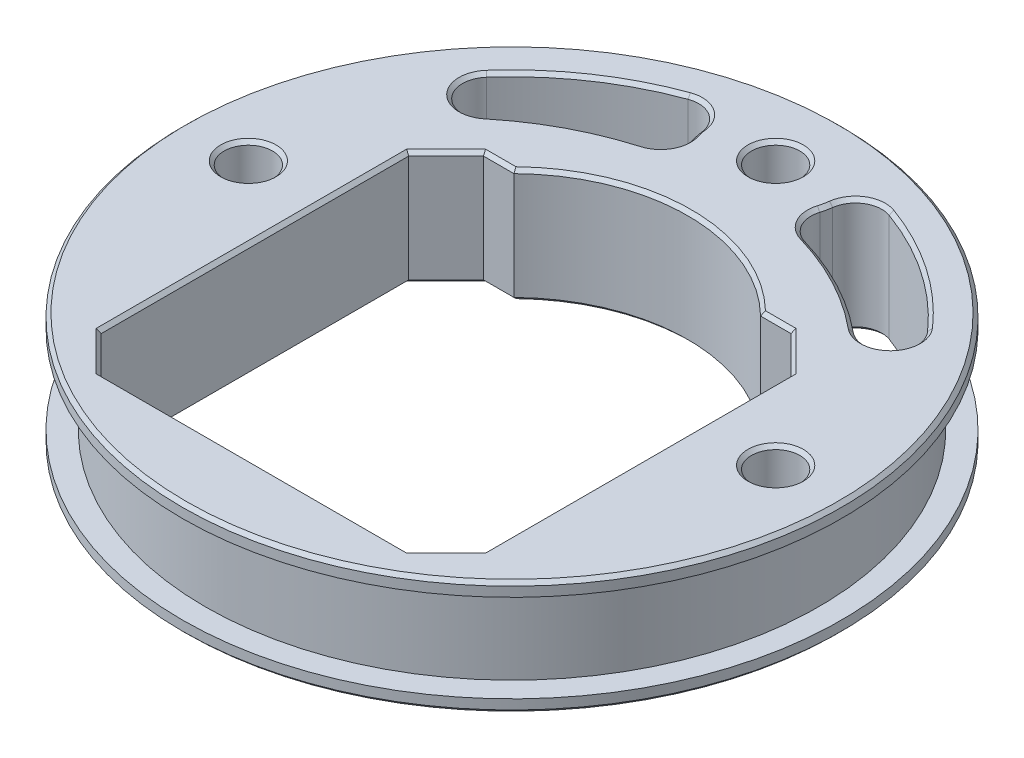
from build123d import *

# Parameters (mm, degrees)
SKETCH1_R               = 37.5
SKETCH1_R_2             = 2.75
BOSS_EXTRUDE1_DEPTH     = 6.5
SKETCH2_R               = 44.9
SKETCH2_R_2             = 34.9
CUT_EXTRUDE_THIN1_DEPTH = 5
CHAMFER1_SIZE           = 0.4
CHAMFER2_SIZE           = 0.4


with BuildPart() as part:
    # Sketch1 → Boss-Extrude1 (new body, symmetric)
    with BuildSketch(Plane(origin=(0, 0, 0), x_dir=(1, 0, 0), z_dir=(0, 1, 0))):
        Circle(SKETCH1_R)
        with Locations((0, 30)):
            Circle(SKETCH1_R_2, mode=Mode.SUBTRACT)
        with Locations((30, 0)):
            Circle(SKETCH1_R_2, mode=Mode.SUBTRACT)
        with Locations((-30, 0)):
            Circle(SKETCH1_R_2, mode=Mode.SUBTRACT)
        with BuildLine():
            Line((-17.494426356, 14.25), (-14.033442201, 14.25))
            ThreePointArc((-14.033442201, 14.25), (0, 20), (14.033442201, 14.25))
            Line((14.033442201, 14.25), (17.494426356, 14.25))
            Line((17.494426356, 14.25), (21.75, 9.994426356))
            Line((21.75, 9.994426356), (21.75, -24.994426356))
            Line((21.75, -24.994426356), (17.494426356, -29.25))
            Line((17.494426356, -29.25), (-17.494426356, -29.25))
            Line((-17.494426356, -29.25), (-21.75, -24.994426356))
            Line((-21.75, -24.994426356), (-21.75, 9.994426356))
            Line((-21.75, 9.994426356), (-17.494426356, 14.25))
        make_face(mode=Mode.SUBTRACT)
        with BuildLine():
            ThreePointArc((7.182286097, 27.840192967), (7.335670337, 28.438609369), (7.439285619, 29.047619048))
            ThreePointArc((7.439285619, 29.047619048), (8.853359783, 31.228166276), (11.439426083, 31.486338798))
            ThreePointArc((11.439426083, 31.486338798), (18.843045333, 27.698188435), (25.085377879, 22.203013684))
            ThreePointArc((25.085377879, 22.203013684), (24.997326571, 18.131103641), (20.931054397, 17.899511222))
            ThreePointArc((20.931054397, 17.899511222), (15.388292289, 21.593722157), (9.215229657, 24.09626166))
            ThreePointArc((9.215229657, 24.09626166), (7.418794885, 25.54470973), (7.182286097, 27.840192967))
        make_face(mode=Mode.SUBTRACT)
        with BuildLine():
            ThreePointArc((-25.085377879, 22.203013684), (-24.997326571, 18.131103641), (-20.931054397, 17.899511222))
            ThreePointArc((-20.931054397, 17.899511222), (-15.388292289, 21.593722157), (-9.215229657, 24.09626166))
            ThreePointArc((-9.215229657, 24.09626166), (-7.418794885, 25.54470973), (-7.182286097, 27.840192967))
            ThreePointArc((-7.182286097, 27.840192967), (-7.335670337, 28.438609369), (-7.439285619, 29.047619048))
            ThreePointArc((-7.439285619, 29.047619048), (-8.853359783, 31.228166276), (-11.439426083, 31.486338798))
            ThreePointArc((-11.439426083, 31.486338798), (-18.843045333, 27.698188435), (-25.085377879, 22.203013684))
        make_face(mode=Mode.SUBTRACT)
    extrude(amount=BOSS_EXTRUDE1_DEPTH, both=True)

    # Sketch2 → Cut-Extrude-Thin1 (cut, symmetric)
    with BuildSketch(Plane(origin=(0, 0, 0), x_dir=(1, 0, 0), z_dir=(0, 1, 0))):
        Circle(SKETCH2_R)
        Circle(SKETCH2_R_2, mode=Mode.SUBTRACT)
    extrude(amount=CUT_EXTRUDE_THIN1_DEPTH, both=True, mode=Mode.SUBTRACT)

    # Chamfer1
    chamfer1_edges = [part.edges().sort_by_distance(p)[0] for p in [
        (-37.5, -6.5, 0),
        (-37.5, 6.5, 0),
    ]]
    chamfer(chamfer1_edges, length=CHAMFER1_SIZE)

    # Chamfer2
    chamfer2_edges = [part.edges().sort_by_distance(p)[0] for p in [
        (-19.622213178, -6.5, -12.122213178),
        (-21.75, -6.5, 7.5),
        (-19.622213178, -6.5, 27.122213178),
        (0, -6.5, 29.25),
        (19.622213178, -6.5, 27.122213178),
        (21.75, -6.5, 7.5),
        (19.622213178, -6.5, -12.122213178),
        (15.763934278, -6.5, -14.25),
        (0, -6.5, -20),
        (-15.763934278, -6.5, -14.25),
        (-19.622213178, 6.5, -12.122213178),
        (-21.75, 6.5, 7.5),
        (-19.622213178, 6.5, 27.122213178),
        (0, 6.5, 29.25),
        (19.622213178, 6.5, 27.122213178),
        (21.75, 6.5, 7.5),
        (19.622213178, 6.5, -12.122213178),
        (15.763934278, 6.5, -14.25),
        (0, 6.5, -20),
        (-15.763934278, 6.5, -14.25),
        (-2.75, -6.5, -30),
        (-2.75, 6.5, -30),
        (27.25, -6.5, 0),
        (27.25, 6.5, 0),
        (-32.75, -6.5, 0),
        (-32.75, 6.5, 0),
        (-15.388292289, -6.5, -21.593722157),
        (-7.418794885, -6.5, -25.54470973),
        (-7.335670337, -6.5, -28.438609369),
        (-8.853359783, -6.5, -31.228166276),
        (-18.843045333, -6.5, -27.698188435),
        (-24.997326571, -6.5, -18.131103641),
        (-15.388292289, 6.5, -21.593722157),
        (-7.418794885, 6.5, -25.54470973),
        (-7.335670337, 6.5, -28.438609369),
        (-8.853359783, 6.5, -31.228166276),
        (-18.843045333, 6.5, -27.698188435),
        (-24.997326571, 6.5, -18.131103641),
        (18.843045333, -6.5, -27.698188435),
        (8.853359783, -6.5, -31.228166276),
        (7.335670337, -6.5, -28.438609369),
        (7.418794885, -6.5, -25.54470973),
        (15.388292289, -6.5, -21.593722157),
        (24.997326571, -6.5, -18.131103641),
        (18.843045333, 6.5, -27.698188435),
        (8.853359783, 6.5, -31.228166276),
        (7.335670337, 6.5, -28.438609369),
        (7.418794885, 6.5, -25.54470973),
        (15.388292289, 6.5, -21.593722157),
        (24.997326571, 6.5, -18.131103641),
    ]]
    chamfer(chamfer2_edges, length=CHAMFER2_SIZE)


solid = part.part
